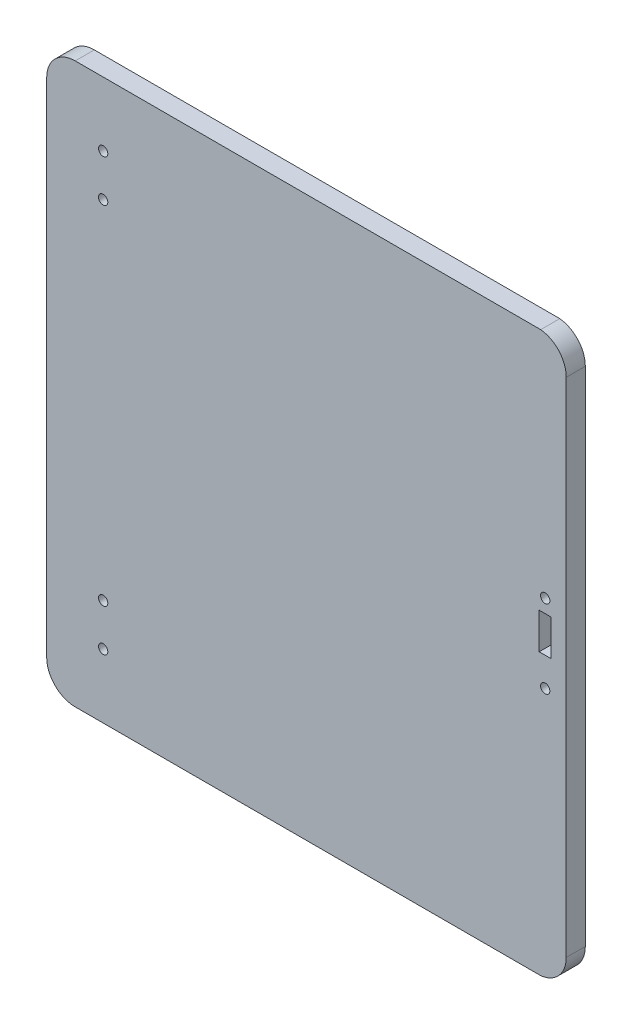
from build123d import *

# Parameters (mm, degrees)
BOSS_EXTRUDE1_DEPTH = 6.35
SKETCH3_W           = 4
SKETCH3_H           = 12
CUT_EXTRUDE1_DEPTH  = 6.35
SKETCH4_R           = 1.55
CUT_EXTRUDE2_DEPTH  = 7.35
SKETCH5_R           = 1.55
CUT_EXTRUDE3_DEPTH  = 7.35


with BuildPart() as part:
    # Sketch2 → Boss-Extrude1 (new body)
    with BuildSketch(Plane.XY):
        with BuildLine():
            Line((77.5, 93.15), (-77.5, 93.15))
            ThreePointArc((-77.5, 93.15), (-84.217514421, 90.367514421), (-87, 83.65))
            Line((-87, 83.65), (-87, -83.65))
            ThreePointArc((-87, -83.65), (-84.217514421, -90.367514421), (-77.5, -93.15))
            Line((-77.5, -93.15), (77.5, -93.15))
            ThreePointArc((77.5, -93.15), (83.579939001, -90.037313843), (86, -83.65))
            Line((86, -83.65), (86, 83.65))
            ThreePointArc((86, 83.65), (83.579939001, 90.037313843), (77.5, 93.15))
        make_face()
    extrude(amount=BOSS_EXTRUDE1_DEPTH)

    # Sketch3 → Cut-Extrude1 (cut)
    with BuildSketch(Plane.XY.offset(6.35)):
        with Locations((79, 6)):
            Rectangle(SKETCH3_W, SKETCH3_H)
    extrude(amount=-CUT_EXTRUDE1_DEPTH, mode=Mode.SUBTRACT)

    # Sketch4 → Cut-Extrude2 (cut, through all)
    with BuildSketch(Plane.XY.offset(6.35)):
        with Locations((-68.2, 71.8)):
            Circle(SKETCH4_R)
        with Locations((-68.2, 57.8)):
            Circle(SKETCH4_R)
        with Locations((-68.2, -57.8)):
            Circle(SKETCH4_R)
        with Locations((-68.2, -71.8)):
            Circle(SKETCH4_R)
    extrude(amount=-CUT_EXTRUDE2_DEPTH, mode=Mode.SUBTRACT)

    # Sketch5 → Cut-Extrude3 (cut, through all)
    with BuildSketch(Plane.XY.offset(6.35)):
        with Locations((79, 16.45)):
            Circle(SKETCH5_R)
        with Locations((79, -9.55)):
            Circle(SKETCH5_R)
    extrude(amount=-CUT_EXTRUDE3_DEPTH, mode=Mode.SUBTRACT)


solid = part.part
